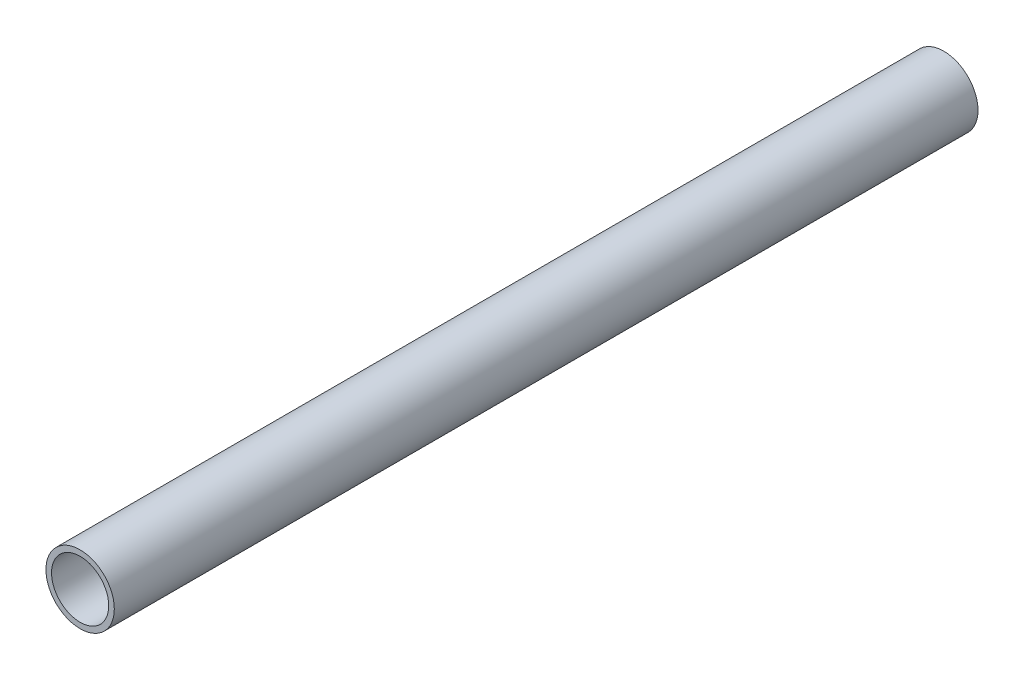
from build123d import *

# Parameters (mm, degrees)
SKETCH1_R           = 24.13
SKETCH1_R_2         = 20.193
BOSS_EXTRUDE1_DEPTH = 609.6


with BuildPart() as part:
    # Sketch1 → Boss-Extrude1 (new body)
    with BuildSketch(Plane.XY):
        Circle(SKETCH1_R)
        Circle(SKETCH1_R_2, mode=Mode.SUBTRACT)
    extrude(amount=BOSS_EXTRUDE1_DEPTH)


solid = part.part
